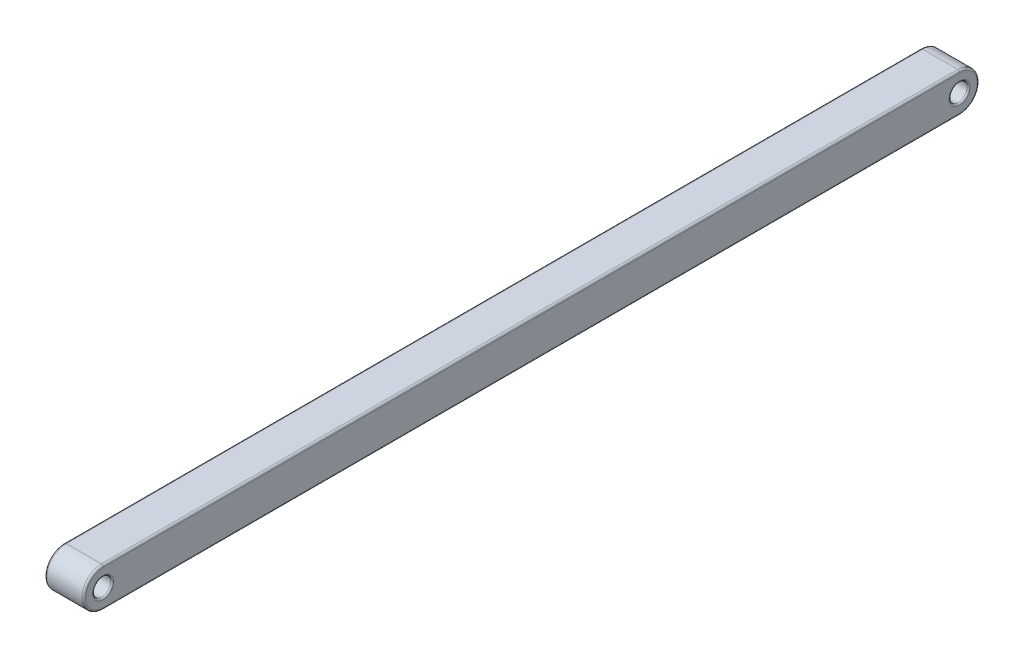
from build123d import *

# Parameters (mm, degrees)
SKETCH1_R           = 0.575
BOSS_EXTRUDE1_DEPTH = 2.5
FILLET1_R           = 0.125
FILLET2_R           = 0.1


with BuildPart() as part:
    # Sketch1 → Boss-Extrude1 (new body)
    with BuildSketch(Plane(origin=(0, 0, 0), x_dir=(0, 0, -1), z_dir=(1, 0, 0))):
        with BuildLine():
            Line((0, 0), (55, 0))
            ThreePointArc((55, 0), (56.25, -1.25), (55, -2.5))
            Line((55, -2.5), (0, -2.5))
            ThreePointArc((0, -2.5), (-1.25, -1.25), (0, 0))
        make_face()
        with Locations((0, -1.25)):
            Circle(SKETCH1_R, mode=Mode.SUBTRACT)
        with Locations((55, -1.25)):
            Circle(SKETCH1_R, mode=Mode.SUBTRACT)
    extrude(amount=BOSS_EXTRUDE1_DEPTH)

    # Fillet1
    fillet1_edges = [part.edges().sort_by_distance(p)[0] for p in [
        (2.5, -1.25, -56.25),
        (2.5, 0, -27.5),
        (2.5, -1.25, 1.25),
        (0, 0, -27.5),
        (0, -1.25, -56.25),
        (0, -2.5, -27.5),
        (0, -1.25, 1.25),
        (2.5, -2.5, -27.5),
    ]]
    fillet(fillet1_edges, radius=FILLET1_R)

    # Fillet2
    fillet2_edges = [part.edges().sort_by_distance(p)[0] for p in [
        (0, -1.25, 0.575),
        (2.5, -1.25, 0.575),
        (0, -1.25, -54.425),
        (2.5, -1.25, -54.425),
    ]]
    fillet(fillet2_edges, radius=FILLET2_R)


solid = part.part
